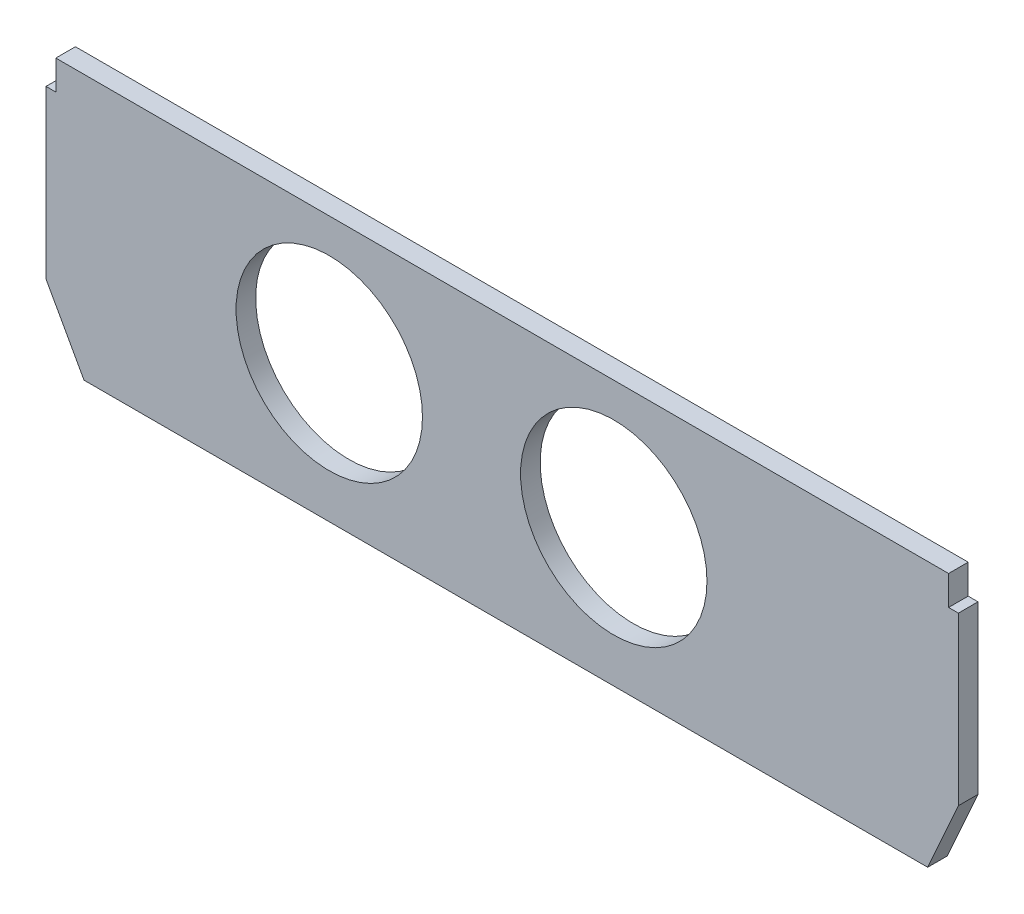
from build123d import *

# Parameters (mm, degrees)
SKETCH2_R           = 60
SKETCH2_R_2         = 47.5
BOSS_EXTRUDE2_DEPTH = 10


with BuildPart() as part:
    # Sketch2 → Boss-Extrude2 (new body)
    with BuildSketch(Plane.XY):
        Polygon((10.635083269, 120), (10.635083269, 135), (-444.364916731, 135), (-444.364916731, 120), (-449.364916731, 120), (-449.364916731, 35), (-430, 0), (0, 0), (15.635083269, 35), (15.635083269, 120), align=None)
        with Locations((-160, 70)):
            Circle(SKETCH2_R, mode=Mode.SUBTRACT)
        with Locations((-305, 70)):
            Circle(SKETCH2_R, mode=Mode.SUBTRACT)
        with Locations((-160, 70)):
            Circle(SKETCH2_R)
        with Locations((-160, 70)):
            Circle(SKETCH2_R_2, mode=Mode.SUBTRACT)
        with Locations((-305, 70)):
            Circle(SKETCH2_R)
        with Locations((-305, 70)):
            Circle(SKETCH2_R_2, mode=Mode.SUBTRACT)
    extrude(amount=BOSS_EXTRUDE2_DEPTH)


solid = part.part
